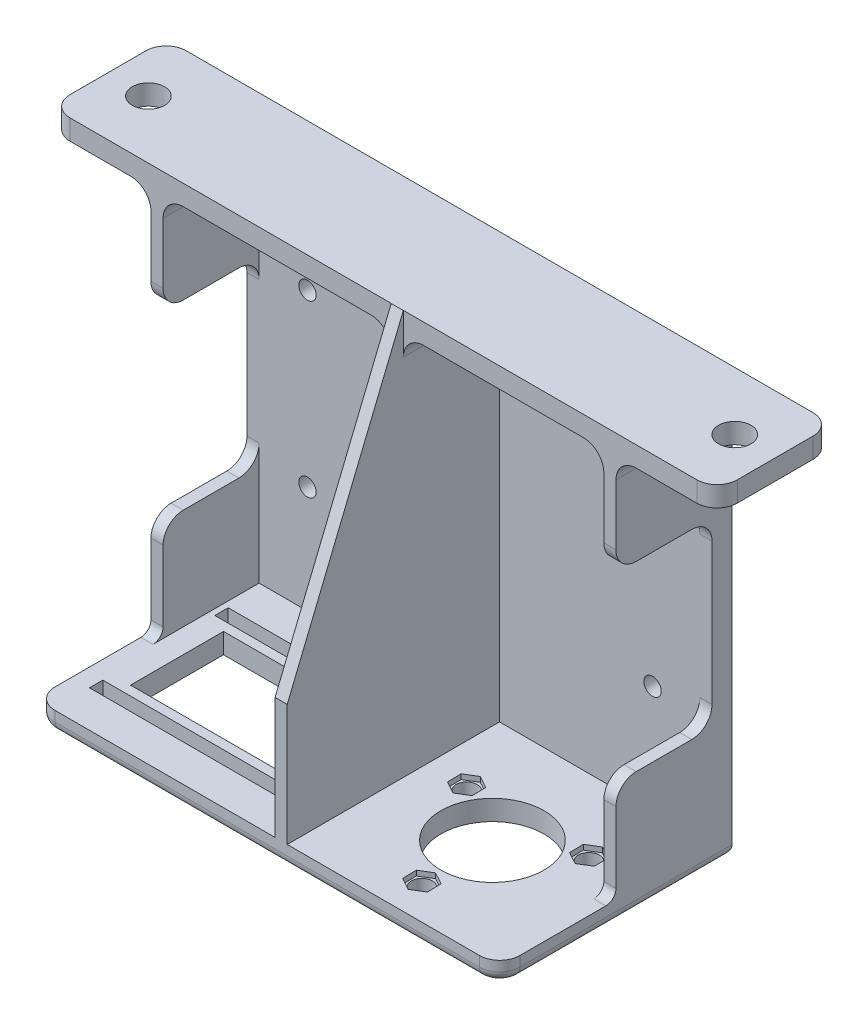
from build123d import *

# Parameters (mm, degrees)
SKETCH2_R           = 2.6
SKETCH2_R_2         = 12.75
BOSS_EXTRUDE1_DEPTH = 5
SKETCH3_W           = 115
SKETCH3_H           = 100
BOSS_EXTRUDE2_DEPTH = 5
SKETCH4_W           = 165
SKETCH4_H           = 28.75
BOSS_EXTRUDE3_DEPTH = 5
SKETCH5_W           = 3
SKETCH5_H           = 95
SKETCH5_H_2         = 25
BOSS_EXTRUDE4_DEPTH = 23.75
SKETCH6_R           = 4
CUT_EXTRUDE1_DEPTH  = 5
SKETCH7_R           = 2.55
CUT_EXTRUDE2_DEPTH  = 1
SKETCH8_R           = 2.15
CUT_EXTRUDE3_DEPTH  = 4
SKETCH9_W           = 3
SKETCH9_H           = 28.75
BOSS_EXTRUDE5_DEPTH = 100
CHAMFER1_SIZE       = 70
CHAMFER1_SIZE2      = 28.709092262
FILLET1_R           = 5
FILLET2_R           = 2.5
CUT_EXTRUDE4_DEPTH  = 1.25


with BuildPart() as part:
    # Sketch2 → Boss-Extrude1 (new body)
    with BuildSketch(Plane.XZ.offset(-21.878326304)):
        Polygon((119.866549827, 74.413081659), (14.866549827, 74.413081659), (4.866549827, 74.413081659), (4.866549827, 21.913081659), (14.866549827, 21.913081659), (119.866549827, 21.913081659), align=None)
        Polygon((9.316549827, 34.313081659), (14.316549827, 34.313081659), (26.316549827, 34.313081659), (57.316549827, 34.313081659), (64.316549827, 34.313081659), (64.316549827, 31.013081659), (57.316549753, 31.013081659), (26.316549827, 31.013081659), (14.316549827, 31.013081659), (9.316549827, 31.013081659), align=None, mode=Mode.SUBTRACT)
        with Locations((76.704406531, 39.438081659)):
            Circle(SKETCH2_R, mode=Mode.SUBTRACT)
        with Locations((106.928693123, 39.438081659)):
            Circle(SKETCH2_R, mode=Mode.SUBTRACT)
        Polygon((13.816549827, 59.663081659), (16.816549827, 59.663081659), (59.816549827, 59.663081659), (59.816549827, 36.663081659), (16.816549827, 36.663081659), (13.816549827, 36.663081659), align=None, mode=Mode.SUBTRACT)
        Polygon((57.316549827, 65.313081659), (64.316549827, 65.313081659), (64.316549827, 62.013081659), (57.316549827, 62.013081659), (26.316549827, 62.013081659), (14.316549827, 62.013081659), (9.316549827, 62.013081659), (9.316549827, 65.313081659), (14.316549827, 65.313081659), (26.316549827, 65.313081659), align=None, mode=Mode.SUBTRACT)
        with Locations((91.816549827, 48.163081659)):
            Circle(SKETCH2_R_2, mode=Mode.SUBTRACT)
        with Locations((91.816549827, 65.613081659)):
            Circle(SKETCH2_R, mode=Mode.SUBTRACT)
    extrude(amount=BOSS_EXTRUDE1_DEPTH)

    # Sketch3 → Boss-Extrude2 (add)
    with BuildSketch(Plane(origin=(0, 0, 21.913081659), x_dir=(-1, 0, 0), z_dir=(0, 0, -1))):
        with Locations((-62.366549827, 66.878326304)):
            Rectangle(SKETCH3_W, SKETCH3_H)
    extrude(amount=BOSS_EXTRUDE2_DEPTH)

    # Sketch4 → Boss-Extrude3 (add)
    with BuildSketch(Plane(origin=(0, 116.878326304, 0), x_dir=(1, 0, 0), z_dir=(0, 1, 0))):
        with Locations((62.366549827, -31.288081659)):
            Rectangle(SKETCH4_W, SKETCH4_H)
    extrude(amount=BOSS_EXTRUDE3_DEPTH)

    # Sketch5 → Boss-Extrude4 (add)
    with BuildSketch(Plane.XY.offset(21.913081659)):
        with Locations((65.816549827, 69.378326304)):
            Rectangle(SKETCH5_W, SKETCH5_H)
        with Locations((118.366549827, 104.378326304)):
            Rectangle(SKETCH5_W, SKETCH5_H_2)
        with Locations((118.366549827, 34.378326304)):
            Rectangle(SKETCH5_W, SKETCH5_H_2)
        with Locations((6.366549827, 34.378326304)):
            Rectangle(SKETCH5_W, SKETCH5_H_2)
        with Locations((6.366549827, 104.378326304)):
            Rectangle(SKETCH5_W, SKETCH5_H_2)
    extrude(amount=BOSS_EXTRUDE4_DEPTH)

    # Sketch6 → Cut-Extrude1 (cut)
    with BuildSketch(Plane(origin=(0, 121.878326304, 0), x_dir=(1, 0, 0), z_dir=(0, 1, 0))):
        with Locations((134.866549827, -31.288081659)):
            Circle(SKETCH6_R)
        with Locations((-10.133450173, -31.288081659)):
            Circle(SKETCH6_R)
    extrude(amount=-CUT_EXTRUDE1_DEPTH, mode=Mode.SUBTRACT)

    # Sketch7 → Cut-Extrude2 (cut)
    with BuildSketch(Plane(origin=(0, 0, 16.913081659), x_dir=(-1, 0, 0), z_dir=(0, 0, -1))):
        with Locations((-105.165549827, 90.587326304)):
            Circle(SKETCH7_R)
        with Locations((-105.165549827, 48.423326304)):
            Circle(SKETCH7_R)
        with Locations((-19.821549827, 48.423326304)):
            Circle(SKETCH7_R)
        with Locations((-19.821549827, 90.587326304)):
            Circle(SKETCH7_R)
    extrude(amount=-CUT_EXTRUDE2_DEPTH, mode=Mode.SUBTRACT)

    # Sketch8 → Cut-Extrude3 (cut)
    with BuildSketch(Plane(origin=(0, 0, 17.913081659), x_dir=(-1, 0, 0), z_dir=(0, 0, -1))):
        with Locations((-105.165549827, 90.587326304)):
            Circle(SKETCH8_R)
        with Locations((-19.825549827, 90.587326304)):
            Circle(SKETCH8_R)
        with Locations((-19.825549827, 48.427326304)):
            Circle(SKETCH8_R)
        with Locations((-105.165549827, 48.427326304)):
            Circle(SKETCH8_R)
    extrude(amount=-CUT_EXTRUDE3_DEPTH, mode=Mode.SUBTRACT)

    # Sketch9 → Boss-Extrude5 (add)
    with BuildSketch(Plane(origin=(0, 21.878326304, 0), x_dir=(1, 0, 0), z_dir=(0, 1, 0))):
        with Locations((65.816549827, -60.038081659)):
            Rectangle(SKETCH9_W, SKETCH9_H)
    extrude(amount=BOSS_EXTRUDE5_DEPTH)

    # Chamfer1
    chamfer1_edges = [part.edges().sort_by_distance(p)[0] for p in [
        (65.816549827, 121.878326304, 74.413081659),
    ]]
    chamfer1_side = [part.faces().sort_by_distance(p)[0] for p in [
        (118.309308677, 19.378326304, 74.413081659),
    ]]
    chamfer(chamfer1_edges, length=CHAMFER1_SIZE, length2=CHAMFER1_SIZE2, reference=chamfer1_side[0])

    # Fillet1
    fillet1_edges = [part.edges().sort_by_distance(p)[0] for p in [
        (67.316549827, 116.878326304, 33.788081659),
        (64.316549827, 116.878326304, 33.788081659),
        (118.366549827, 91.878326304, 45.663081659),
        (118.366549827, 91.878326304, 21.913081659),
        (116.866549827, 116.878326304, 33.788081659),
        (118.366549827, 46.878326304, 45.663081659),
        (118.366549827, 46.878326304, 21.913081659),
        (6.366549827, 46.878326304, 45.663081659),
        (6.366549827, 46.878326304, 21.913081659),
        (7.866549827, 116.878326304, 33.788081659),
        (6.366549827, 91.878326304, 45.663081659),
        (6.366549827, 91.878326304, 21.913081659),
        (119.866549827, 19.378326304, 74.413081659),
        (4.866549827, 19.378326304, 74.413081659),
        (119.866549827, 116.878326304, 31.288081659),
        (4.866549827, 116.878326304, 31.288081659),
        (-20.133450173, 119.378326304, 16.913081659),
        (-20.133450173, 119.378326304, 45.663081659),
        (144.866549827, 119.378326304, 45.663081659),
        (144.866549827, 119.378326304, 16.913081659),
    ]]
    fillet(fillet1_edges, radius=FILLET1_R)

    # Fillet2
    fillet2_edges = [part.edges().sort_by_distance(p)[0] for p in [
        (118.366549827, 21.878326304, 45.663081659),
        (6.366549827, 21.878326304, 45.663081659),
        (119.866549827, 16.878326304, 43.163081659),
        (4.866549827, 16.878326304, 43.163081659),
        (62.366549827, 16.878326304, 74.413081659),
        (118.402083733, 16.878326304, 72.948615565),
        (6.331015921, 16.878326304, 72.948615565),
        (62.366549827, 16.878326304, 16.913081659),
    ]]
    fillet(fillet2_edges, radius=FILLET2_R)

    # Sketch10 → Cut-Extrude4 (cut)
    with BuildSketch(Plane(origin=(0, 21.878326304, 0), x_dir=(1, 0, 0), z_dir=(0, 1, 0))):
        Polygon((106.849185334, -35.980469853), (103.894559568, -37.778131521), (103.974067356, -41.235743327), (107.008200912, -42.895693466), (109.962826678, -41.098031798), (109.883318889, -37.640419991), align=None)
        Polygon((73.749780764, -41.235743327), (76.78391432, -42.895693466), (79.738540086, -41.098031798), (79.659032297, -37.640419991), (76.624898742, -35.980469853), (73.670272976, -37.778131521), align=None)
        Polygon((94.850683382, -67.273031798), (94.771175593, -63.815419991), (91.737042038, -62.155469853), (88.782416272, -63.953131521), (88.86192406, -67.410743327), (91.896057616, -69.070693466), align=None)
    extrude(amount=-CUT_EXTRUDE4_DEPTH, mode=Mode.SUBTRACT)


solid = part.part
